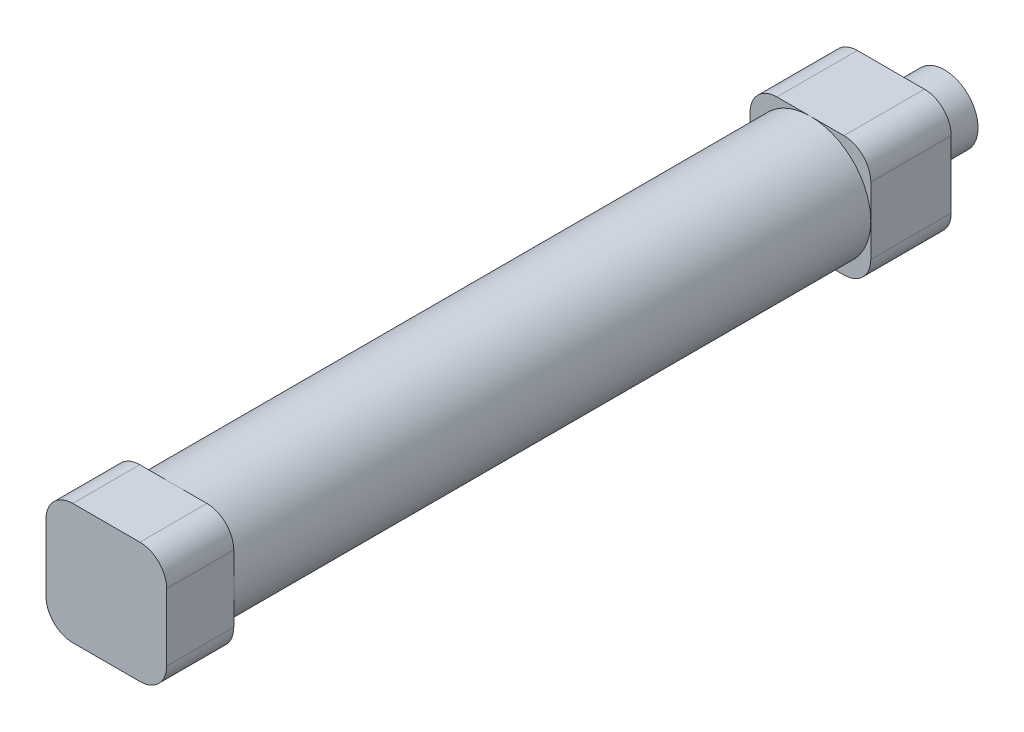
from build123d import *

# Parameters (mm, degrees)
SKETCH_1_R          = 9
SKETCH_1_R_2        = 8
EXTRUDE_1_DEPTH     = 95
EXTRUDE_2_DEPTH     = 10
EXTRUDE_3_DEPTH     = 12
SKETCH_4_R          = 5
EXTRUDE_4_DEPTH     = 8
SKETCH_5_R          = 2.5
CUT_EXTRUDE_1_DEPTH = 38
SKETCH_6_R          = 2
SKETCH_6_R_2        = 1.980516498
CUT_EXTRUDE_3_DEPTH = 3


with BuildPart() as part:
    # 草图1 → 凸台-拉伸1 (new body)
    with BuildSketch(Plane.XY):
        Circle(SKETCH_1_R)
        Circle(SKETCH_1_R_2, mode=Mode.SUBTRACT)
    extrude(amount=EXTRUDE_1_DEPTH)

    # 草图2 → 凸台-拉伸2 (add)
    with BuildSketch(Plane.XY.offset(95)):
        with BuildLine():
            Line((-5, -9), (5, -9))
            ThreePointArc((5, -9), (7.828427125, -7.828427125), (9, -5))
            Line((9, -5), (9, 5))
            ThreePointArc((9, 5), (7.828427125, 7.828427125), (5, 9))
            Line((5, 9), (-5, 9))
            ThreePointArc((-5, 9), (-7.828427125, 7.828427125), (-9, 5))
            Line((-9, 5), (-9, -5))
            ThreePointArc((-9, -5), (-7.828427125, -7.828427125), (-5, -9))
        make_face()
    extrude(amount=EXTRUDE_2_DEPTH)

    # 草图3 → 凸台-拉伸3 (add)
    with BuildSketch(Plane(origin=(0, 0, 0), x_dir=(-1, 0, 0), z_dir=(0, 0, -1))):
        with BuildLine():
            Line((-5, -9), (5, -9))
            ThreePointArc((5, -9), (7.828427125, -7.828427125), (9, -5))
            Line((9, -5), (9, 5))
            ThreePointArc((9, 5), (7.828427125, 7.828427125), (5, 9))
            Line((5, 9), (-5, 9))
            ThreePointArc((-5, 9), (-7.828427125, 7.828427125), (-9, 5))
            Line((-9, 5), (-9, -5))
            ThreePointArc((-9, -5), (-7.828427125, -7.828427125), (-5, -9))
        make_face()
    extrude(amount=EXTRUDE_3_DEPTH)

    # 草图4 → 凸台-拉伸4 (add)
    with BuildSketch(Plane(origin=(0, 0, -12), x_dir=(-1, 0, 0), z_dir=(0, 0, -1))):
        Circle(SKETCH_4_R)
    extrude(amount=EXTRUDE_4_DEPTH)

    # 草图5 → 切除-拉伸1 (cut)
    with BuildSketch(Plane(origin=(0, 0, -20), x_dir=(-1, 0, 0), z_dir=(0, 0, -1))):
        Circle(SKETCH_5_R)
    extrude(amount=-CUT_EXTRUDE_1_DEPTH, mode=Mode.SUBTRACT)

    # 草图6 → 切除-拉伸3 (cut)
    with BuildSketch(Plane.ZY.offset(9)):
        with Locations((-4, 0)):
            Circle(SKETCH_6_R)
        with Locations((99, 0)):
            Circle(SKETCH_6_R_2)
    extrude(amount=-CUT_EXTRUDE_3_DEPTH, mode=Mode.SUBTRACT)


solid = part.part
